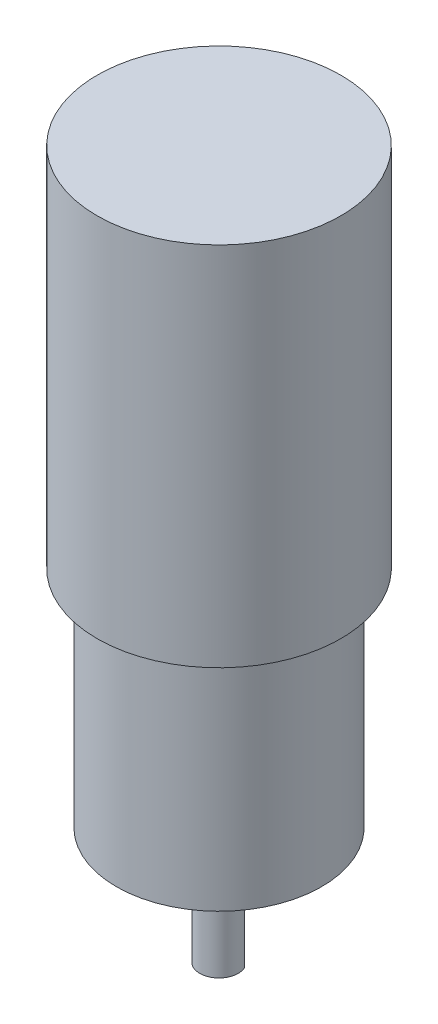
from build123d import *

# Parameters (mm, degrees)
BOSS_EXTRUDE1_DEPTH = 12
BOSS_EXTRUDE2_DEPTH = 3.2
BOSS_EXTRUDE3_DEPTH = 3
SKETCH6_R           = 16
BOSS_EXTRUDE4_DEPTH = 35
SKETCH7_R           = 19
BOSS_EXTRUDE5_DEPTH = 57.1
SKETCH8_R           = 1.5
CUT_EXTRUDE1_DEPTH  = 10


with BuildPart() as part:
    # Sketch2 → Boss-Extrude1 (new body)
    with BuildSketch(Plane(origin=(0, 0, 0), x_dir=(1, 0, 0), z_dir=(0, 1, 0))):
        with BuildLine():
            Line((2.75, 1.198957881), (-2.75, 1.198957881))
            ThreePointArc((-2.75, 1.198957881), (-0.612372436, -2.936835031), (3, 0))
            ThreePointArc((3, 0), (2.936835031, 0.612372436), (2.75, 1.198957881))
        make_face()
    extrude(amount=BOSS_EXTRUDE1_DEPTH)

    # Sketch3 → Boss-Extrude2 (add)
    with BuildSketch(Plane(origin=(0, 12, 0), x_dir=(1, 0, 0), z_dir=(0, 1, 0))):
        with BuildLine():
            Line((2.75, 1.198957881), (-2.75, 1.198957881))
            ThreePointArc((-2.75, 1.198957881), (-0.612372436, -2.936835031), (3, 0))
            ThreePointArc((3, 0), (2.936835031, 0.612372436), (2.75, 1.198957881))
        make_face()
        with BuildLine():
            ThreePointArc((2.75, 1.198957881), (0, 3), (-2.75, 1.198957881))
            Line((-2.75, 1.198957881), (2.75, 1.198957881))
        make_face()
        with BuildLine():
            ThreePointArc((-2.75, 1.198957881), (0, -3), (2.75, 1.198957881))
            Line((2.75, 1.198957881), (-2.75, 1.198957881))
        make_face()
    extrude(amount=BOSS_EXTRUDE2_DEPTH)

    # Sketch5 → Boss-Extrude3 (add)
    with BuildSketch(Plane(origin=(0, 15.2, 0), x_dir=(1, 0, 0), z_dir=(0, 1, 0))):
        with BuildLine():
            Line((-9, 4.358898944), (-9, -4.358898944))
            ThreePointArc((-9, -4.358898944), (0, -10), (9, -4.358898944))
            Line((9, -4.358898944), (9, 4.358898944))
            ThreePointArc((9, 4.358898944), (0, 10), (-9, 4.358898944))
        make_face()
    extrude(amount=BOSS_EXTRUDE3_DEPTH)

    # Sketch6 → Boss-Extrude4 (add)
    with BuildSketch(Plane(origin=(0, 18.2, 0), x_dir=(1, 0, 0), z_dir=(0, 1, 0))):
        Circle(SKETCH6_R)
    extrude(amount=BOSS_EXTRUDE4_DEPTH)

    # Sketch7 → Boss-Extrude5 (add)
    with BuildSketch(Plane(origin=(0, 53.2, 0), x_dir=(1, 0, 0), z_dir=(0, 1, 0))):
        Circle(SKETCH7_R)
    extrude(amount=BOSS_EXTRUDE5_DEPTH)

    # Sketch8 → Cut-Extrude1 (cut)
    with BuildSketch(Plane.XZ.offset(-18.2)):
        with Locations((0, 13)):
            Circle(SKETCH8_R)
        with Locations((13, 0)):
            Circle(SKETCH8_R)
        with Locations((0, -13)):
            Circle(SKETCH8_R)
        with Locations((-13, 0)):
            Circle(SKETCH8_R)
    extrude(amount=-CUT_EXTRUDE1_DEPTH, mode=Mode.SUBTRACT)


solid = part.part
